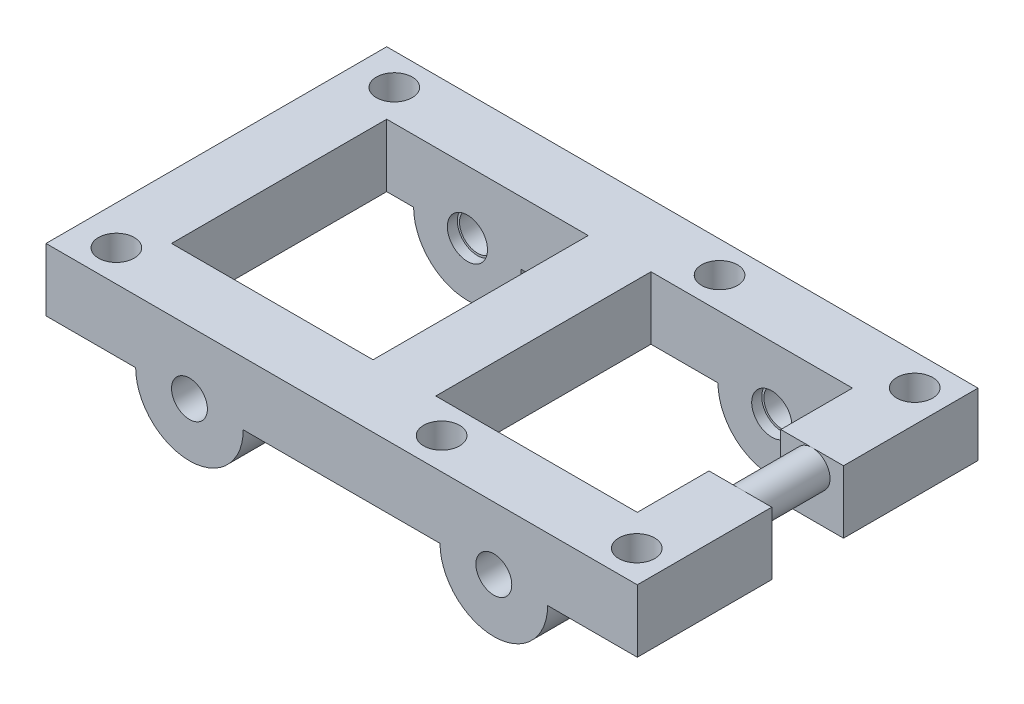
from build123d import *

# Parameters (mm, degrees)
SKETCH1_W                    = 104.687624
SKETCH1_H                    = 60.325
SKETCH1_W_2                  = 35.675062
SKETCH1_H_2                  = 38.1
BOSS_EXTRUDE1_DEPTH          = 11.1125
BOSS_EXTRUDE32_DEPTH         = 11.1125
BOSS_EXTRUDE36_START         = -49.2125
BOSS_EXTRUDE36_DEPTH         = 11.1125
CUT_EXTRUDE1_REACH           = 22.637
SKETCH9_W                    = 11.1125
SKETCH9_H                    = 12.7
BOSS_EXTRUDE37_REACH         = 38.512
SKETCH10_R                   = 3.175
F_97_0_0059_DIAMETER_HOLE1_D = 6.35
SKETCH17_R                   = 3.556
CUT_EXTRUDE2_DEPTH           = 1.778
SKETCH18_R                   = 3.556
CUT_EXTRUDE3_DEPTH           = 1.778
SKETCH19_R                   = 3.175
CUT_EXTRUDE4_DEPTH           = 5.842
SKETCH20_R                   = 3.556
CUT_EXTRUDE7_DEPTH           = 6.842
CUT_EXTRUDE7_DEPTH_BACK      = 15.7955
SKETCH24_R                   = 3.556
SKETCH24_R_2                 = 3.175
BOSS_EXTRUDE40_DEPTH         = 5.842


with BuildPart() as part:
    # Sketch1 → Boss-Extrude1 (new body)
    with BuildSketch(Plane(origin=(0, 0, 0), x_dir=(1, 0, 0), z_dir=(0, 1, 0))):
        with Locations((52.343812, 30.1625)):
            Rectangle(SKETCH1_W, SKETCH1_H)
        with Locations((28.950031, 30.1625)):
            Rectangle(SKETCH1_W_2, SKETCH1_H_2, mode=Mode.SUBTRACT)
        with Locations((75.737593, 30.1625)):
            Rectangle(SKETCH1_W_2, SKETCH1_H_2, mode=Mode.SUBTRACT)
    extrude(amount=BOSS_EXTRUDE1_DEPTH)

    # Sketch2 → Boss-Extrude32 (add)
    with BuildSketch(Plane.XY):
        with BuildLine():
            Line((0, 11.1125), (0, 0))
            Line((0, 0), (15.875, 0))
            ThreePointArc((15.875, 0), (25.4, -9.525), (34.925, 0))
            Line((34.925, 0), (69.762624, 0))
            ThreePointArc((69.762624, 0), (79.287624, -9.525), (88.812624, 0))
            Line((88.812624, 0), (104.687624, 0))
            Line((104.687624, 0), (104.687624, 11.1125))
            Line((104.687624, 11.1125), (0, 11.1125))
        make_face()
    extrude(amount=-BOSS_EXTRUDE32_DEPTH)

    # Sketch2_11 → Boss-Extrude36 (add)
    with BuildSketch(Plane.XY.offset(BOSS_EXTRUDE36_START)):
        with BuildLine():
            Line((0, 11.1125), (0, 0))
            Line((0, 0), (15.875, 0))
            ThreePointArc((15.875, 0), (25.4, -9.525), (34.925, 0))
            Line((34.925, 0), (69.762624, 0))
            ThreePointArc((69.762624, 0), (79.287624, -9.525), (88.812624, 0))
            Line((88.812624, 0), (104.687624, 0))
            Line((104.687624, 0), (104.687624, 11.1125))
            Line((104.687624, 11.1125), (0, 11.1125))
        make_face()
    extrude(amount=-BOSS_EXTRUDE36_DEPTH)

    # Sketch9 → Cut-Extrude1 (cut, up to next)
    with BuildSketch(Plane(origin=(0, 11.1125, 0), x_dir=(1, 0, 0), z_dir=(0, 1, 0)), mode=Mode.PRIVATE) as cut_extrude1_sk1:
        with Locations((99.131374, 30.1625)):
            Rectangle(SKETCH9_W, SKETCH9_H)
    cut_extrude1_tool1 = extrude(cut_extrude1_sk1.sketch, amount=-CUT_EXTRUDE1_REACH, mode=Mode.PRIVATE) & part.part
    add(cut_extrude1_tool1.solids().sort_by_distance((99.131374, 11.1125, -30.1625))[0], mode=Mode.SUBTRACT)

    # Sketch10 → Boss-Extrude37 (add, up to next)
    with BuildSketch(Plane.XY.offset(-36.5125), mode=Mode.PRIVATE) as boss_extrude37_sk1:
        with Locations((99.131374, 7.9375)):
            Circle(SKETCH10_R)
    boss_extrude37_tool1 = extrude(boss_extrude37_sk1.sketch, amount=BOSS_EXTRUDE37_REACH, mode=Mode.PRIVATE) - part.part
    add(boss_extrude37_tool1.solids().sort_by_distance((99.131374, 7.9375, -36.5125))[0])

    # 97 _0.0059_ Diameter Hole1 (through all)
    with Locations(Plane.XY):
        with Locations((25.4, 0), (79.287624, 0)):
            Hole(F_97_0_0059_DIAMETER_HOLE1_D / 2)

    # Sketch17 → Cut-Extrude2 (cut)
    with BuildSketch(Plane(origin=(0, 0, -11.1125), x_dir=(-1, 0, 0), z_dir=(0, 0, -1))):
        with Locations((-25.4, 0)):
            Circle(SKETCH17_R)
        with Locations((-79.287624, 0)):
            Circle(SKETCH17_R)
    extrude(amount=-CUT_EXTRUDE2_DEPTH, mode=Mode.SUBTRACT)

    # Sketch18 → Cut-Extrude3 (cut)
    with BuildSketch(Plane.XY.offset(-49.2125)):
        with Locations((25.4, 0)):
            Circle(SKETCH18_R)
        with Locations((79.287624, 0)):
            Circle(SKETCH18_R)
    extrude(amount=-CUT_EXTRUDE3_DEPTH, mode=Mode.SUBTRACT)

    # Sketch19 → Cut-Extrude4 (cut)
    with BuildSketch(Plane(origin=(0, 11.1125, 0), x_dir=(1, 0, 0), z_dir=(0, 1, 0))):
        with Locations((99.036124, 54.76875)):
            Circle(SKETCH19_R)
        with Locations((64.487044, 54.76875)):
            Circle(SKETCH19_R)
        with Locations((-40.811196, 54.76875)):
            Circle(SKETCH19_R)
        with Locations((99.036124, 5.55625)):
            Circle(SKETCH19_R)
        with Locations((64.487044, 5.55625)):
            Circle(SKETCH19_R)
        with Locations((-40.811196, 5.55625)):
            Circle(SKETCH19_R)
    extrude(amount=-CUT_EXTRUDE4_DEPTH, mode=Mode.SUBTRACT)

    # Sketch20 → Cut-Extrude7 (cut, two sides)
    with BuildSketch(Plane(origin=(0, 5.2705, 0), x_dir=(1, 0, 0), z_dir=(0, 1, 0))) as cut_extrude7_sk:
        with Locations((99.036124, 54.76875)):
            Circle(SKETCH20_R)
        with Locations((64.487044, 54.76875)):
            Circle(SKETCH20_R)
        with Locations((6.90118, 54.76875)):
            Circle(SKETCH20_R)
        with Locations((6.90118, 5.55625)):
            Circle(SKETCH20_R)
        with Locations((64.487044, 5.55625)):
            Circle(SKETCH20_R)
        with Locations((99.036124, 5.55625)):
            Circle(SKETCH20_R)
    extrude(amount=CUT_EXTRUDE7_DEPTH, mode=Mode.SUBTRACT)
    extrude(cut_extrude7_sk.sketch, amount=-CUT_EXTRUDE7_DEPTH_BACK, mode=Mode.SUBTRACT)

    # Sketch24 → Boss-Extrude40 (add)
    with BuildSketch(Plane(origin=(0, 11.1125, 0), x_dir=(1, 0, 0), z_dir=(0, 1, 0))):
        with Locations((64.487044, 5.55625)):
            Circle(SKETCH24_R)
        with Locations((64.487044, 5.55625)):
            Circle(SKETCH24_R_2, mode=Mode.SUBTRACT)
        with Locations((6.90118, 54.76875)):
            Circle(SKETCH24_R)
        with Locations((6.90118, 54.76875)):
            Circle(SKETCH24_R_2, mode=Mode.SUBTRACT)
        with Locations((64.487044, 54.76875)):
            Circle(SKETCH24_R)
        with Locations((64.487044, 54.76875)):
            Circle(SKETCH24_R_2, mode=Mode.SUBTRACT)
        with Locations((99.036124, 54.76875)):
            Circle(SKETCH24_R)
        with Locations((99.036124, 54.76875)):
            Circle(SKETCH24_R_2, mode=Mode.SUBTRACT)
        with Locations((99.036124, 5.55625)):
            Circle(SKETCH24_R)
        with Locations((99.036124, 5.55625)):
            Circle(SKETCH24_R_2, mode=Mode.SUBTRACT)
        with Locations((6.90118, 5.55625)):
            Circle(SKETCH24_R)
        with Locations((6.90118, 5.55625)):
            Circle(SKETCH24_R_2, mode=Mode.SUBTRACT)
    extrude(amount=-BOSS_EXTRUDE40_DEPTH)


solid = part.part
